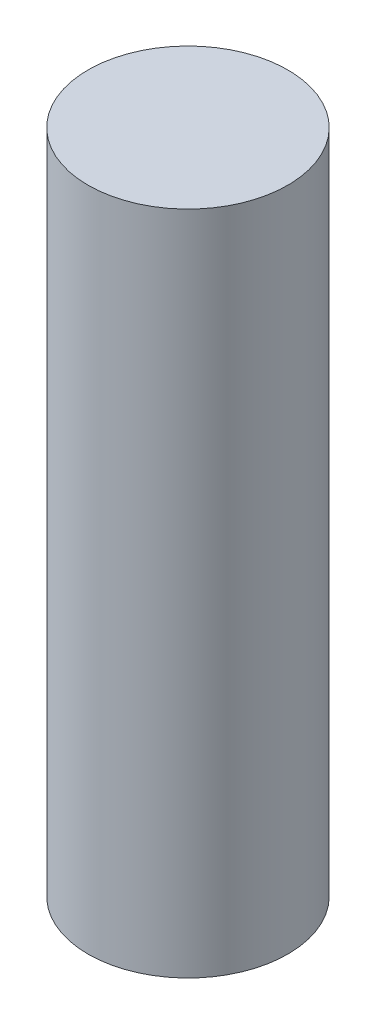
from build123d import *

# Parameters (mm, degrees)
SKETCH1_R           = 3.048
BOSS_EXTRUDE1_DEPTH = 20.32


with BuildPart() as part:
    # Sketch1 → Boss-Extrude1 (new body)
    with BuildSketch(Plane(origin=(0, 0, 0), x_dir=(1, 0, 0), z_dir=(0, 1, 0))):
        with Locations((22.352, 0)):
            Circle(SKETCH1_R)
    extrude(amount=BOSS_EXTRUDE1_DEPTH)


solid = part.part
